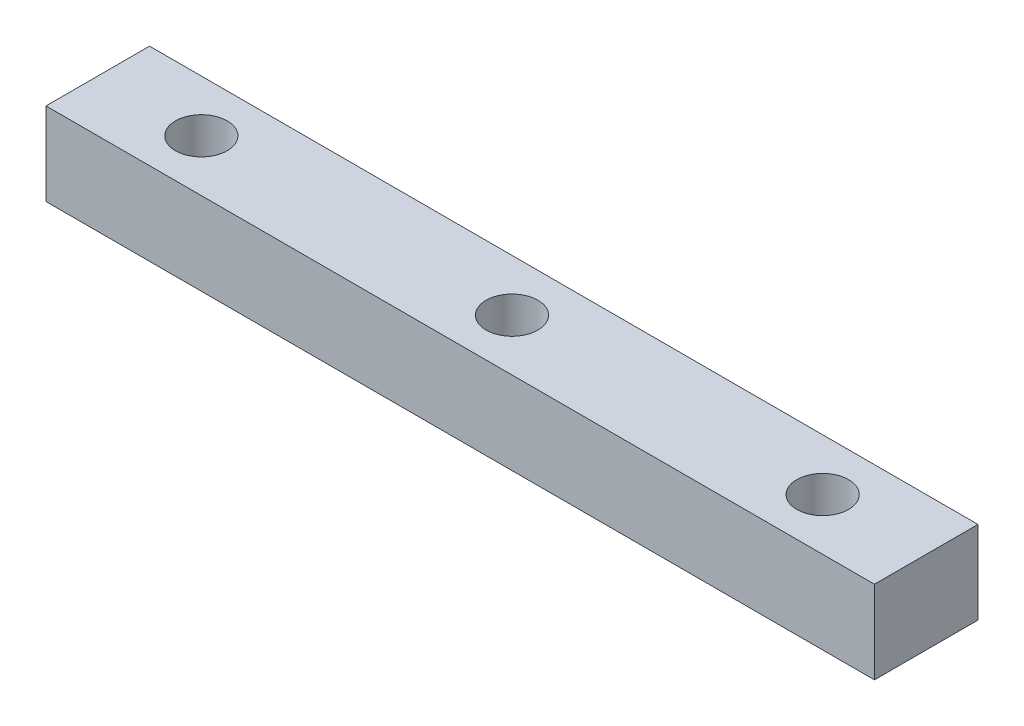
from build123d import *

# Parameters (mm, degrees)
SKETCH_1_W      = 40
SKETCH_1_H      = 5
SKETCH_1_R      = 1.25
EXTRUDE_1_DEPTH = 4


with BuildPart() as part:
    # 스케치1 → 보스-돌출1 (new body)
    with BuildSketch(Plane(origin=(0, 0, 0), x_dir=(1, 0, 0), z_dir=(0, 1, 0))):
        Rectangle(SKETCH_1_W, SKETCH_1_H)
        Circle(SKETCH_1_R, mode=Mode.SUBTRACT)
        with Locations((15, 0)):
            Circle(SKETCH_1_R, mode=Mode.SUBTRACT)
        with Locations((-15, 0)):
            Circle(SKETCH_1_R, mode=Mode.SUBTRACT)
    extrude(amount=EXTRUDE_1_DEPTH)


solid = part.part
